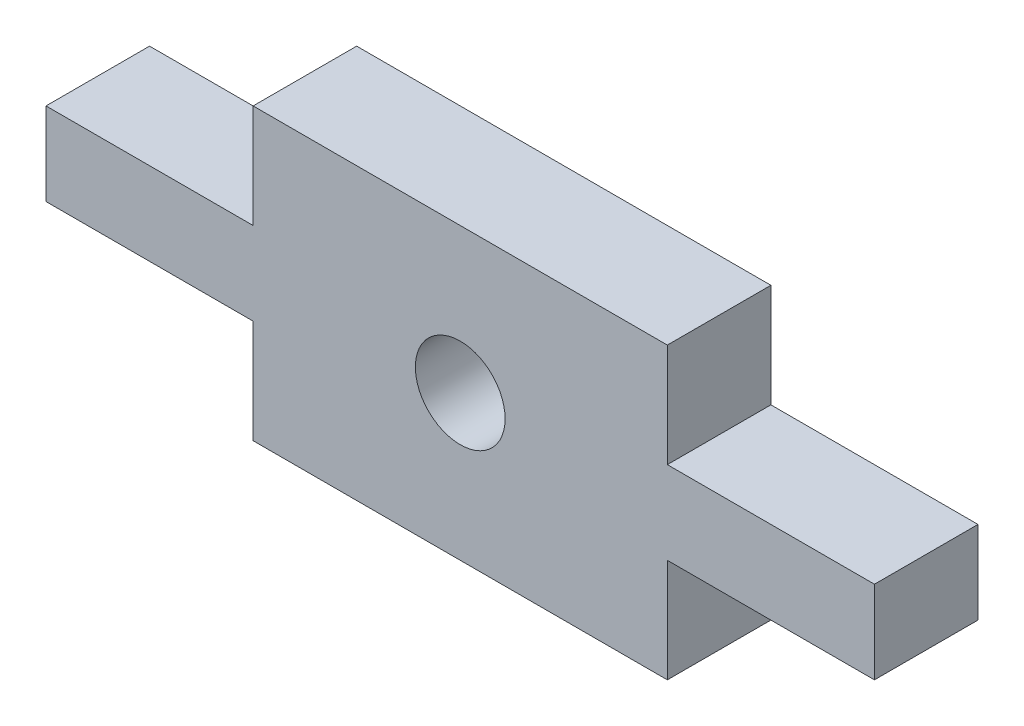
from build123d import *

# Parameters (mm, degrees)
MODEL_R             = 1.300004807
BOSS_EXTRUDE1_DEPTH = 3


with BuildPart() as part:
    # Model → Boss-Extrude1 (new body)
    with BuildSketch(Plane.XY):
        Polygon((50.000171704, 37.800155294), (62.000171704, 37.800155294), (62.000171704, 40.800155294), (67.999966985, 40.800155294), (67.999966985, 43.200155294), (62.000171704, 43.200155294), (62.000171704, 46.200155294), (50.000171704, 46.200155294), (50.000171704, 43.200155294), (44.000136348, 43.200155294), (44.000136348, 40.800155294), (50.000171704, 40.800155294), align=None)
        with Locations((56.00027777, 42.000155294)):
            Circle(MODEL_R, mode=Mode.SUBTRACT)
    extrude(amount=BOSS_EXTRUDE1_DEPTH)


solid = part.part
